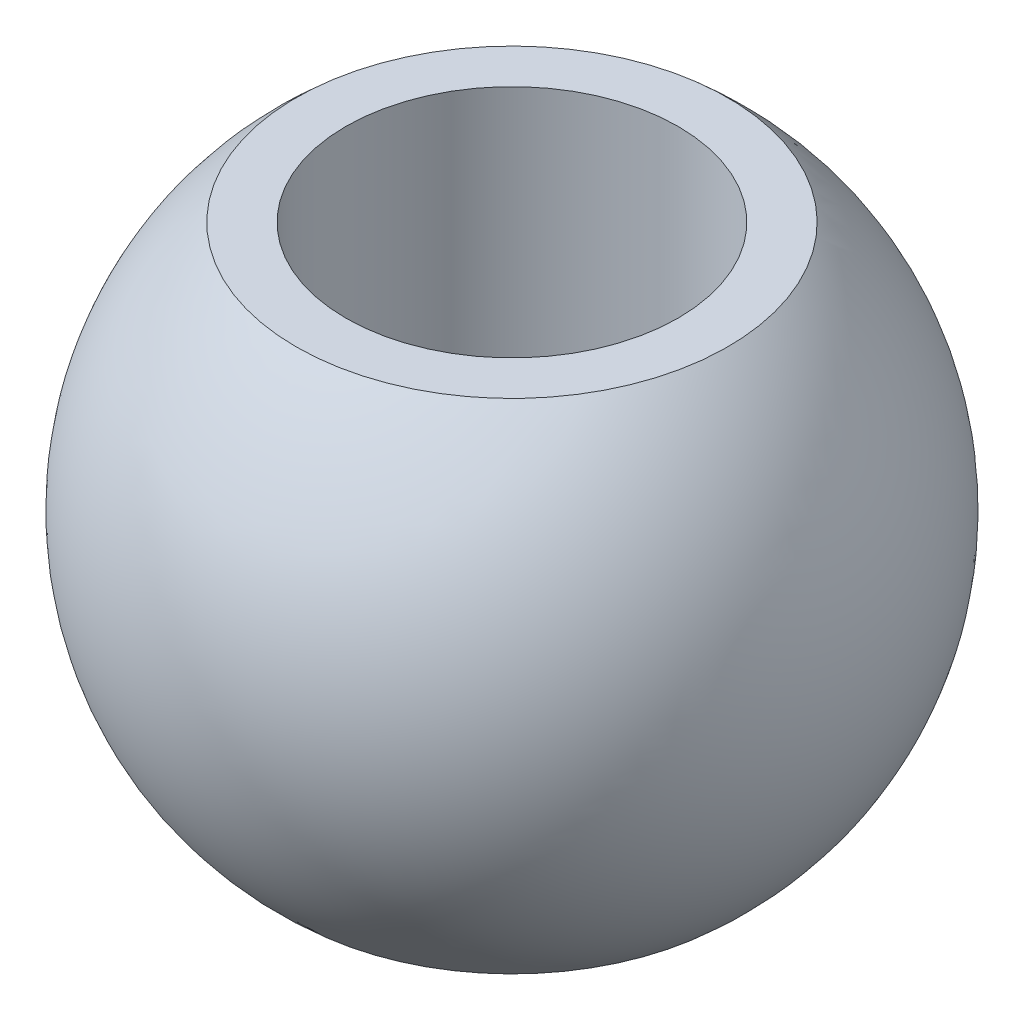
from build123d import *

# Parameters (mm, degrees)
CUT_EXTRUDE1_DEPTH      = 14.748153285
CUT_EXTRUDE1_DEPTH_BACK = 14.748153285
SKETCH2_R               = 4
CUT_EXTRUDE2_DEPTH      = 14.748153285
CUT_EXTRUDE2_DEPTH_BACK = 14.748153285
SKETCH3_W               = 30
SKETCH3_H               = 18
SKETCH3_W_2             = 15.875
SKETCH3_H_2             = 12


with BuildPart() as part:
    # Sketch1 → Revolve1 (revolve)
    with BuildSketch(Plane(origin=(0, 0, 0), x_dir=(1, 0, 0), z_dir=(0, 1, 0))):
        with BuildLine():
            Line((7.9375, 0), (-7.9375, 0))
            ThreePointArc((-7.9375, 0), (0, -7.9375), (7.9375, 0))
        make_face()
    revolve(axis=Axis((7.9375, 0, 0), (-1, 0, 0)))

    # Sketch2 → Cut-Extrude1 (cut, two sides: drawn at the far end of the back side and taken through both)
    with BuildSketch(Plane(origin=(0, 0, 0), x_dir=(1, 0, 0), z_dir=(0, 1, 0)).offset(-CUT_EXTRUDE1_DEPTH_BACK)):
        with Locations(Location((0, 0, 0), (0, 0, 90))):
            Circle(SKETCH2_R)
    extrude(amount=CUT_EXTRUDE1_DEPTH + CUT_EXTRUDE1_DEPTH_BACK, mode=Mode.SUBTRACT)

    # Sketch3 → Cut-Extrude2 (cut, two sides: drawn at the far end of the back side and taken through both)
    with BuildSketch(Plane(origin=(0, 0, 0), x_dir=(0, 0, -1), z_dir=(1, 0, 0)).offset(-CUT_EXTRUDE2_DEPTH_BACK)):
        Rectangle(SKETCH3_W, SKETCH3_H)
        Rectangle(SKETCH3_W_2, SKETCH3_H_2, mode=Mode.SUBTRACT)
    extrude(amount=CUT_EXTRUDE2_DEPTH + CUT_EXTRUDE2_DEPTH_BACK, mode=Mode.SUBTRACT)


solid = part.part
